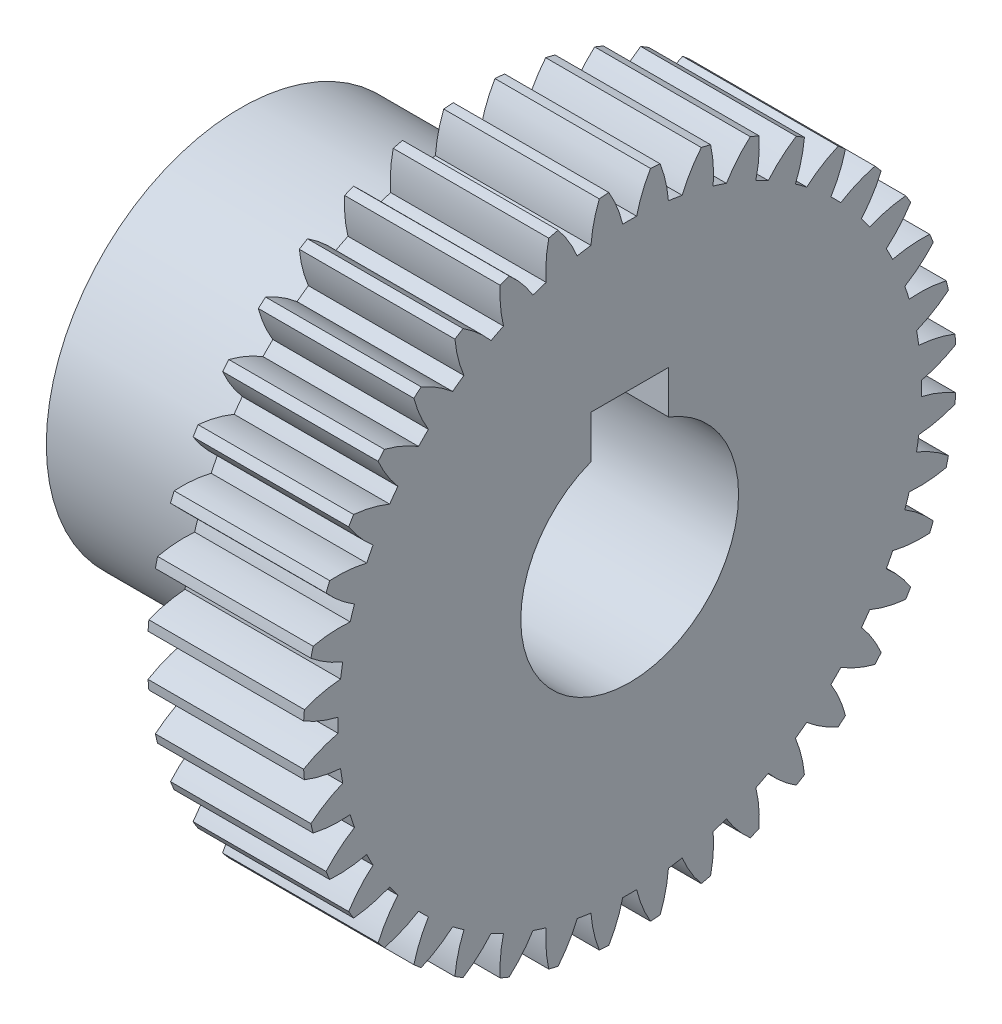
from build123d import *

# Parameters (mm, degrees)
BASPROSKE_W      = 10
BASPROSKE_H      = 21
TOOTHCUT_DEPTH   = 32.336879232
TEETHCUTS_COUNT  = 40
TEETHCUTS_ANGLE  = 351
HUBNEAONESKE_R   = 12.5
HUBNEARONE_DEPTH = 15.0000508
BORSKE_R         = 7
BORE_DEPTH       = 25.0000508
KEYSKE_W         = 5
KEYSKE_H         = 9.3
KEYWAY_DEPTH     = 25.0000508


with BuildPart() as part:
    # BasProSke → Base-Revolve (revolve)
    with BuildSketch(Plane(origin=(0, 0, 0), x_dir=(1, 0, 0), z_dir=(0, 1, 0)), mode=Mode.PRIVATE) as base_revolve_sk:
        with Locations((5, 10.5)):
            Rectangle(BASPROSKE_W, BASPROSKE_H)
    revolve(base_revolve_sk.sketch.rotate(Axis((-10, 0, 0), (1, 0, 0)), 180), axis=Axis((-10, 0, 0), (1, 0, 0)))

    # TooCutSke → ToothCut (cut, through all)
    with BuildSketch(Plane(origin=(0, 0, 0), x_dir=(0, 0, -1), z_dir=(1, 0, 0))):
        with BuildLine():
            ThreePointArc((0.448673268, 18.74363074), (0, 18.749), (-0.448673268, 18.74363074))
            ThreePointArc((-0.448673268, 18.74363074), (-0.816786816, 19.89705013), (-1.354745081, 20.981708961))
            ThreePointArc((-1.354745081, 20.981708961), (0, 21.0254), (1.354745081, 20.981708961))
            ThreePointArc((1.354745081, 20.981708961), (0.816786816, 19.89705013), (0.448673268, 18.74363074))
        make_face()
    toothcut = extrude(amount=TOOTHCUT_DEPTH, mode=Mode.SUBTRACT)

    # TeethCuts: ToothCut ×40 about axis
    teethcuts_axis = Axis((-10, 0, 0), (1, 0, 0))
    for i in range(1, TEETHCUTS_COUNT):
        add(toothcut.rotate(teethcuts_axis, i * TEETHCUTS_ANGLE / (TEETHCUTS_COUNT - 1)), mode=Mode.SUBTRACT)

    # HubNeaOneSke → HubNearOne (add)
    with BuildSketch(Plane.ZY):
        with Locations(Location((0, 0, 0), (0, 0, 180))):
            Circle(HUBNEAONESKE_R)
    extrude(amount=HUBNEARONE_DEPTH)

    # BorSke → Bore (cut, symmetric)
    with BuildSketch(Plane(origin=(0, 0, 0), x_dir=(0, 0, -1), z_dir=(1, 0, 0))):
        with Locations(Location((0, 0, 0), (0, 0, 180))):
            Circle(BORSKE_R)
    extrude(amount=BORE_DEPTH, both=True, mode=Mode.SUBTRACT)

    # KeySke → Keyway (cut, symmetric)
    with BuildSketch(Plane(origin=(0, 0, 0), x_dir=(0, 0, -1), z_dir=(1, 0, 0))):
        with Locations((0, 4.65)):
            Rectangle(KEYSKE_W, KEYSKE_H)
    extrude(amount=KEYWAY_DEPTH, both=True, mode=Mode.SUBTRACT)


solid = part.part
